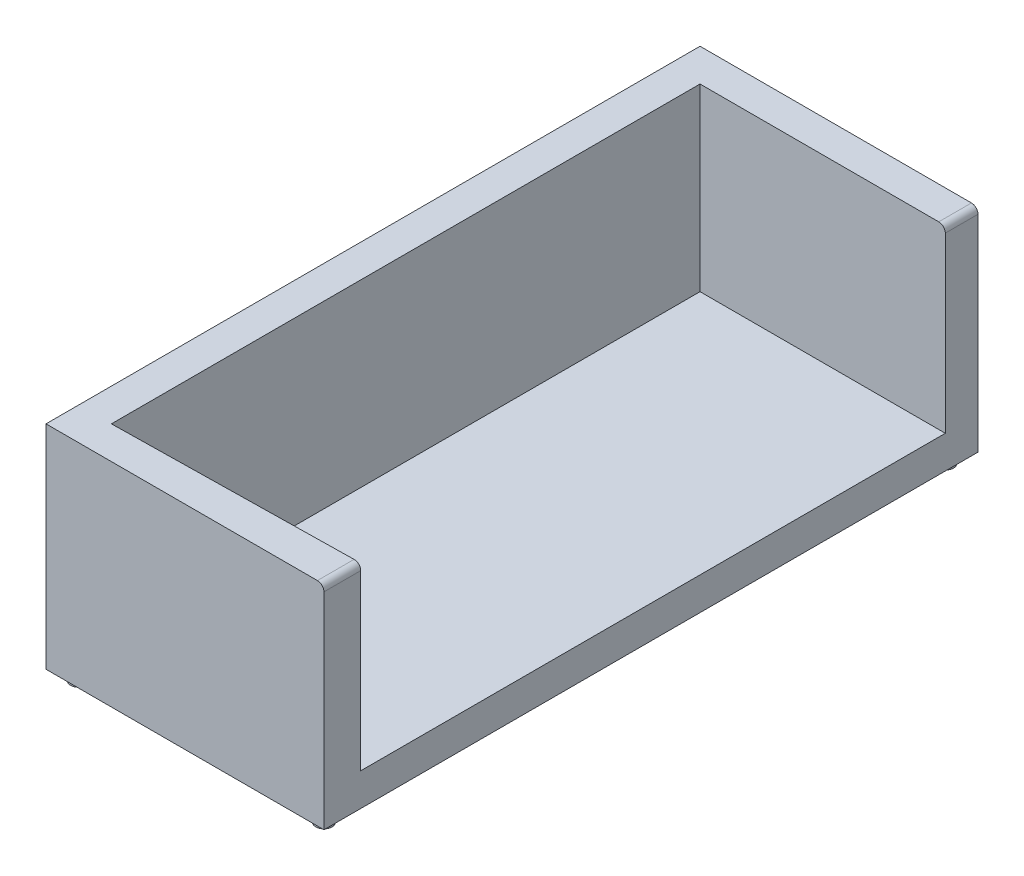
from build123d import *

# Parameters (mm, degrees)
BOSS_EXTRUDE1_DEPTH = 2000
CUT_EXTRUDE1_DEPTH  = 550
SKETCH4_R           = 25
BOSS_EXTRUDE2_DEPTH = 30


with BuildPart() as part:
    # Sketch1 → Boss-Extrude1 (new body)
    with BuildSketch(Plane.XY):
        with BuildLine():
            Line((-425, 270.9650644), (405, 270.9650644))
            ThreePointArc((405, 270.9650644), (419.142135624, 265.107200024), (425, 250.9650644))
            Line((425, 250.9650644), (425, -379.0349356))
            Line((425, -379.0349356), (-425, -379.0349356))
            Line((-425, -379.0349356), (-425, 270.9650644))
        make_face()
    extrude(amount=BOSS_EXTRUDE1_DEPTH)

    # Sketch3 → Cut-Extrude1 (cut)
    with BuildSketch(Plane(origin=(0, 270.9650644, 0), x_dir=(1, 0, 0), z_dir=(0, 1, 0))):
        Polygon((-325, -100), (425, -100), (425, -1887.575015641), (-325, -1900), align=None)
    extrude(amount=-CUT_EXTRUDE1_DEPTH, mode=Mode.SUBTRACT)

    # Sketch4 → Boss-Extrude2 (add)
    with BuildSketch(Plane(origin=(0, -379.0349356, 0), x_dir=(-1, 0, 0), z_dir=(0, -1, 0))):
        with Locations((375, -1950)):
            Circle(SKETCH4_R)
        with Locations((-375, -1950)):
            Circle(SKETCH4_R)
        with Locations((375, -50)):
            Circle(SKETCH4_R)
        with Locations((-375, -50)):
            Circle(SKETCH4_R)
    extrude(amount=BOSS_EXTRUDE2_DEPTH)


solid = part.part
